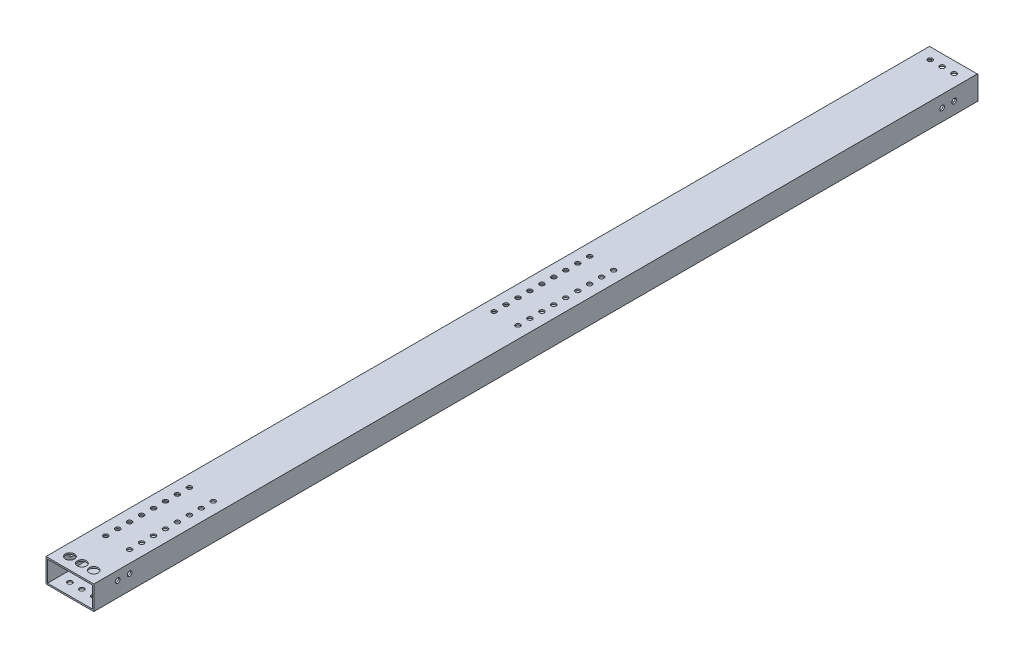
from build123d import *

# Parameters (mm, degrees)
SKETCH1_W           = 50.8
SKETCH1_H           = 25.4
SKETCH1_W_2         = 47.625
SKETCH1_H_2         = 22.225
BOSS_EXTRUDE1_DEPTH = 469.9
SKETCH4_R           = 4.826
CUT_EXTRUDE3_DEPTH  = 1.5875
SKETCH5_R           = 2.5527
CUT_EXTRUDE4_DEPTH  = 1.5875
SKETCH6_R           = 2.5527
CUT_EXTRUDE5_DEPTH  = 26.4
SKETCH7_R           = 2.5527
SKETCH7_R_2         = 2.4892
CUT_EXTRUDE6_DEPTH  = 51.8
SKETCH10_R          = 2.4892
CUT_EXTRUDE8_DEPTH  = 1.5875
CHAMFER1_SIZE       = 0.762


with BuildPart() as part:
    # Sketch1 → Boss-Extrude1 (new body, symmetric)
    with BuildSketch(Plane.XY):
        Rectangle(SKETCH1_W, SKETCH1_H)
        Rectangle(SKETCH1_W_2, SKETCH1_H_2, mode=Mode.SUBTRACT)
    extrude(amount=BOSS_EXTRUDE1_DEPTH, both=True)

    # Sketch4 → Cut-Extrude3 (cut)
    with BuildSketch(Plane(origin=(0, 12.7, 0), x_dir=(1, 0, 0), z_dir=(0, 1, 0))):
        with Locations((-12.7, -457.2)):
            Circle(SKETCH4_R)
        with Locations((0, -457.2)):
            Circle(SKETCH4_R)
        with Locations((12.7, -457.2)):
            Circle(SKETCH4_R)
    extrude(amount=-CUT_EXTRUDE3_DEPTH, mode=Mode.SUBTRACT)

    # Sketch5 → Cut-Extrude4 (cut)
    with BuildSketch(Plane.XZ.offset(12.7)):
        with Locations((12.7, 457.2)):
            Circle(SKETCH5_R)
        with Locations((0, 457.2)):
            Circle(SKETCH5_R)
        with Locations((-12.7, 457.2)):
            Circle(SKETCH5_R)
    extrude(amount=-CUT_EXTRUDE4_DEPTH, mode=Mode.SUBTRACT)

    # Sketch6 → Cut-Extrude5 (cut, through all)
    with BuildSketch(Plane.XZ.offset(12.7)):
        with Locations((12.7, -457.2)):
            Circle(SKETCH6_R)
        with Locations((0, -457.2)):
            Circle(SKETCH6_R)
        with Locations((-12.7, -457.2)):
            Circle(SKETCH6_R)
    extrude(amount=-CUT_EXTRUDE5_DEPTH, mode=Mode.SUBTRACT)

    # Sketch7 → Cut-Extrude6 (cut, through all)
    with BuildSketch(Plane(origin=(25.4, 0, 0), x_dir=(0, 0, -1), z_dir=(1, 0, 0))):
        with Locations((431.8, 0)):
            Circle(SKETCH7_R)
        with Locations((444.5, 0)):
            Circle(SKETCH7_R)
        with Locations((-444.5, 3.175)):
            Circle(SKETCH7_R_2)
        with Locations((-431.8, 3.175)):
            Circle(SKETCH7_R_2)
    extrude(amount=-CUT_EXTRUDE6_DEPTH, mode=Mode.SUBTRACT)

    # Sketch10 → Cut-Extrude8 (cut)
    with BuildSketch(Plane(origin=(0, 12.7, 0), x_dir=(1, 0, 0), z_dir=(0, 1, 0))):
        with Locations((-12.7, -419.1)):
            Circle(SKETCH10_R)
        with Locations((12.7, -419.1)):
            Circle(SKETCH10_R)
        with Locations((-12.7, -406.4)):
            Circle(SKETCH10_R)
        with Locations((12.7, -406.4)):
            Circle(SKETCH10_R)
        with Locations((-12.7, -393.7)):
            Circle(SKETCH10_R)
        with Locations((12.7, -393.7)):
            Circle(SKETCH10_R)
        with Locations((-12.7, -381)):
            Circle(SKETCH10_R)
        with Locations((12.7, -381)):
            Circle(SKETCH10_R)
        with Locations((-12.7, -368.3)):
            Circle(SKETCH10_R)
        with Locations((12.7, -368.3)):
            Circle(SKETCH10_R)
        with Locations((-12.7, -355.6)):
            Circle(SKETCH10_R)
        with Locations((12.7, -355.6)):
            Circle(SKETCH10_R)
        with Locations((-12.7, -342.9)):
            Circle(SKETCH10_R)
        with Locations((12.7, -342.9)):
            Circle(SKETCH10_R)
        with Locations((-12.7, -330.2)):
            Circle(SKETCH10_R)
        with Locations((12.7, -330.2)):
            Circle(SKETCH10_R)
        with Locations((-12.7, -6.35)):
            Circle(SKETCH10_R)
        with Locations((12.7, -6.35)):
            Circle(SKETCH10_R)
        with Locations((-12.7, 6.35)):
            Circle(SKETCH10_R)
        with Locations((12.7, 6.35)):
            Circle(SKETCH10_R)
        with Locations((-12.7, 19.05)):
            Circle(SKETCH10_R)
        with Locations((12.7, 19.05)):
            Circle(SKETCH10_R)
        with Locations((-12.7, 31.75)):
            Circle(SKETCH10_R)
        with Locations((12.7, 31.75)):
            Circle(SKETCH10_R)
        with Locations((-12.7, 44.45)):
            Circle(SKETCH10_R)
        with Locations((12.7, 44.45)):
            Circle(SKETCH10_R)
        with Locations((-12.7, 57.15)):
            Circle(SKETCH10_R)
        with Locations((12.7, 57.15)):
            Circle(SKETCH10_R)
        with Locations((-12.7, 69.85)):
            Circle(SKETCH10_R)
        with Locations((12.7, 69.85)):
            Circle(SKETCH10_R)
        with Locations((-12.7, 82.55)):
            Circle(SKETCH10_R)
        with Locations((12.7, 82.55)):
            Circle(SKETCH10_R)
        with Locations((-12.7, 95.25)):
            Circle(SKETCH10_R)
        with Locations((12.7, 95.25)):
            Circle(SKETCH10_R)
    extrude(amount=-CUT_EXTRUDE8_DEPTH, mode=Mode.SUBTRACT)

    # Chamfer1
    chamfer1_edges = [part.edges().sort_by_distance(p)[0] for p in [
        (0, 12.7, -469.9),
    ]]
    chamfer(chamfer1_edges, length=CHAMFER1_SIZE)


solid = part.part
